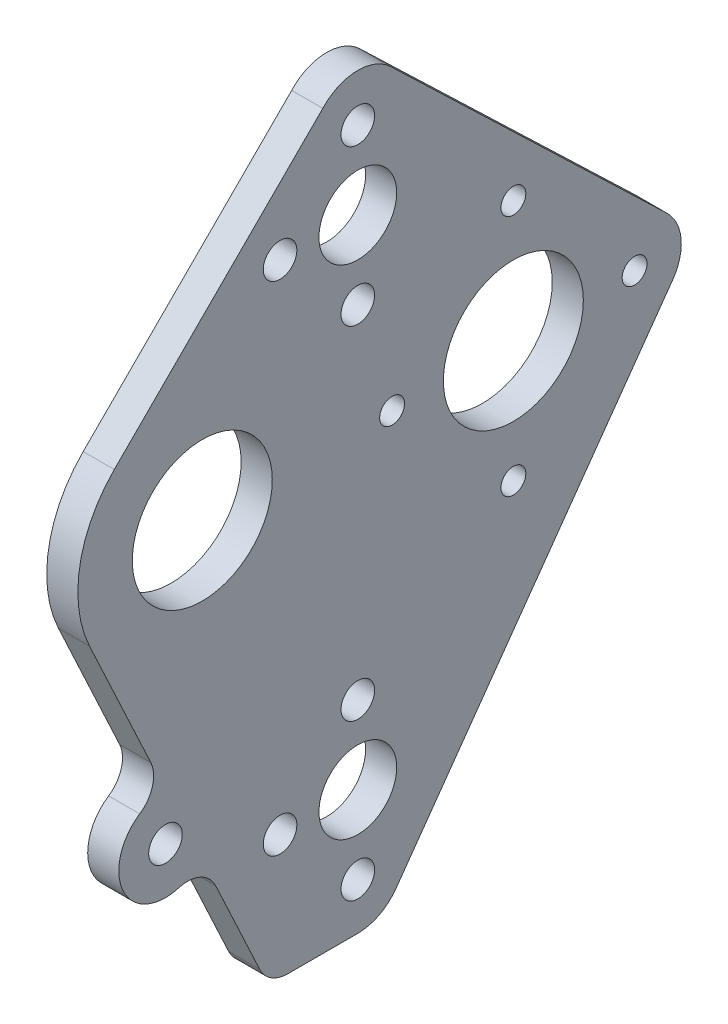
from build123d import *

# Parameters (mm, degrees)
SKETCH1_R           = 14.2875
SKETCH1_R_2         = 7.9375
SKETCH1_R_3         = 3.429
SKETCH1_R_4         = 2.54
BOSS_EXTRUDE1_DEPTH = 6.35


with BuildPart() as part:
    # Sketch1 → Boss-Extrude1 (new body)
    with BuildSketch(Plane(origin=(0, 0, 0), x_dir=(0, 0, -1), z_dir=(1, 0, 0))):
        with BuildLine():
            Line((12.7, -88.9), (-1.575652176, -88.9))
            ThreePointArc((-1.575652176, -88.9), (-4.987504689, -87.905535681), (-7.330706623, -85.233625962))
            Line((-7.330706623, -85.233625962), (-16.304501832, -65.989260033))
            ThreePointArc((-16.304501832, -65.989260033), (-19.450268482, -62.883748133), (-23.860481018, -62.583619201))
            ThreePointArc((-23.860481018, -62.583619201), (-35.194449796, -57.475157953), (-31.822423449, -45.509178558))
            ThreePointArc((-31.822423449, -45.509178558), (-29.217505575, -41.937840594), (-29.574405884, -37.53185896))
            Line((-29.574405884, -37.53185896), (-42.070217791, -10.734503848))
            ThreePointArc((-42.070217791, -10.734503848), (-44.064116927, 4.410663713), (-37.010512242, 17.960512242))
            Line((-37.010512242, 17.960512242), (5.544864644, 60.515889128))
            ThreePointArc((5.544864644, 60.515889128), (12.382451565, 63.66408435), (19.411500847, 60.970351952))
            Line((19.411500847, 60.970351952), (75.796601185, 6.873195536))
            ThreePointArc((75.796601185, 6.873195536), (78.685483549, 0.891546289), (76.962077301, -5.523719874))
            Line((76.962077301, -5.523719874), (20.459777301, -84.898719874))
            ThreePointArc((20.459777301, -84.898719874), (17.065328922, -87.840785752), (12.7, -88.9))
        make_face()
        with Locations((-19.05, 0)):
            Circle(SKETCH1_R, mode=Mode.SUBTRACT)
        with Locations((12.7, 38.1)):
            Circle(SKETCH1_R_2, mode=Mode.SUBTRACT)
        with Locations((12.7, -63.5)):
            Circle(SKETCH1_R_2, mode=Mode.SUBTRACT)
        with Locations((-26.561868124, -53.44971901)):
            Circle(SKETCH1_R_3, mode=Mode.SUBTRACT)
        with Locations((12.7, 53.975)):
            Circle(SKETCH1_R_3, mode=Mode.SUBTRACT)
        with Locations((-3.175, -63.5)):
            Circle(SKETCH1_R_3, mode=Mode.SUBTRACT)
        with Locations((12.7, -47.625)):
            Circle(SKETCH1_R_3, mode=Mode.SUBTRACT)
        with Locations((12.7, -79.375)):
            Circle(SKETCH1_R_3, mode=Mode.SUBTRACT)
        with Locations((-3.175, 38.1)):
            Circle(SKETCH1_R_3, mode=Mode.SUBTRACT)
        with Locations((12.7, 22.225)):
            Circle(SKETCH1_R_3, mode=Mode.SUBTRACT)
        with Locations((44.45, 0)):
            Circle(SKETCH1_R, mode=Mode.SUBTRACT)
        with Locations((44.45, 24.7523)):
            Circle(SKETCH1_R_4, mode=Mode.SUBTRACT)
        with Locations((69.2023, 0)):
            Circle(SKETCH1_R_4, mode=Mode.SUBTRACT)
        with Locations((44.45, -24.7523)):
            Circle(SKETCH1_R_4, mode=Mode.SUBTRACT)
        with Locations((19.6977, 0)):
            Circle(SKETCH1_R_4, mode=Mode.SUBTRACT)
    extrude(amount=BOSS_EXTRUDE1_DEPTH)


solid = part.part
